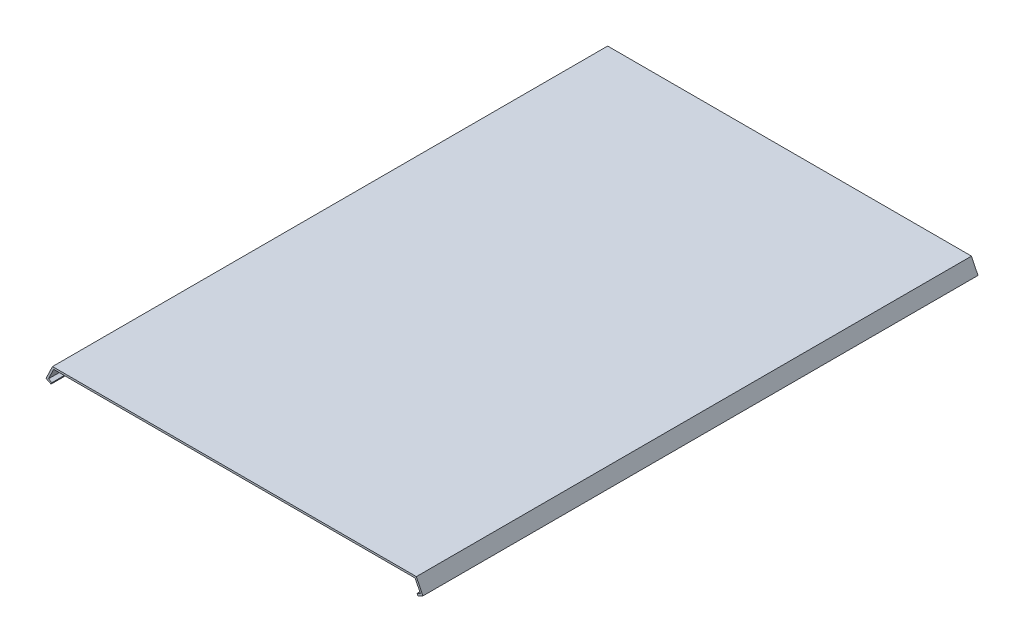
from build123d import *

# Parameters (mm, degrees)
EXTRUSION1_DEPTH = 148


with BuildPart() as part:
    # Esquisse1 → Extrusion1 (new body, symmetric)
    with BuildSketch(Plane.XY):
        Polygon((-96.371723749, -1), (-99.13684937, -6.740465471), (-97.334993013, -7.608401914), (-97.768961234, -8.509330092), (-100.47174577, -7.207425429), (-97, 0), (97, 0), (100.47174577, -7.207425429), (97.768961234, -8.509330092), (97.334993013, -7.608401914), (99.13684937, -6.740465471), (96.371723749, -1), align=None)
    extrude(amount=EXTRUSION1_DEPTH, both=True)


solid = part.part
